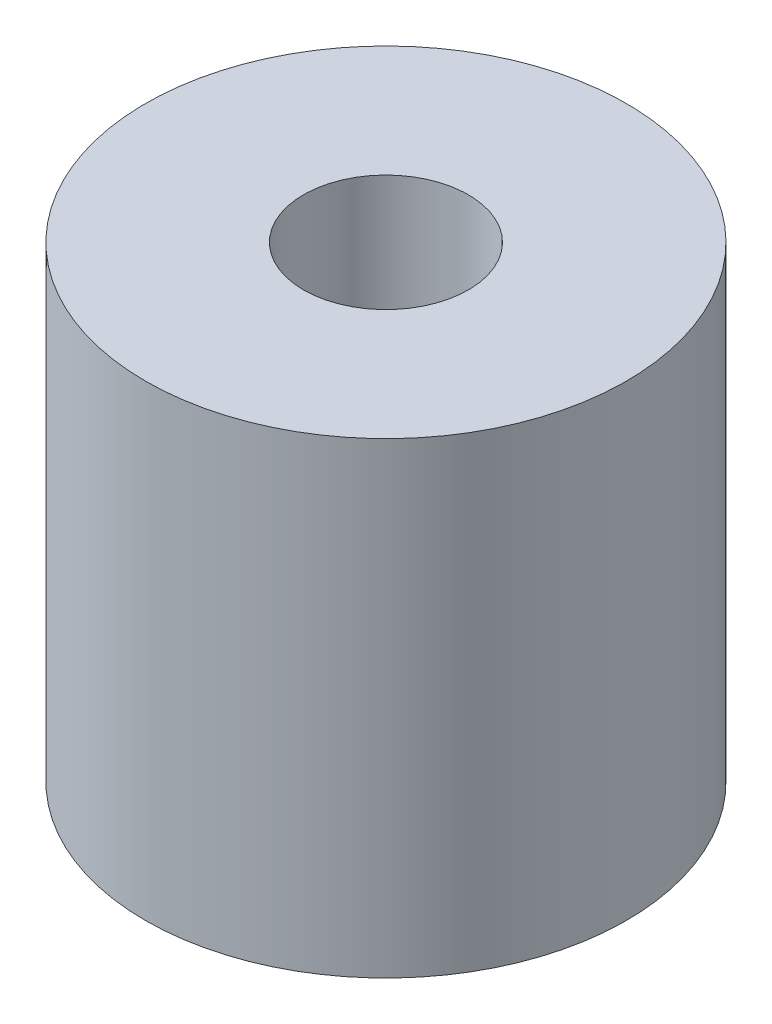
from build123d import *

# Parameters (mm, degrees)
SKETCH1_R           = 35
SKETCH1_R_2         = 12
BOSS_EXTRUDE1_DEPTH = 68


with BuildPart() as part:
    # Sketch1 → Boss-Extrude1 (new body)
    with BuildSketch(Plane(origin=(0, 0, 0), x_dir=(1, 0, 0), z_dir=(0, 1, 0))):
        Circle(SKETCH1_R)
        Circle(SKETCH1_R_2, mode=Mode.SUBTRACT)
    extrude(amount=BOSS_EXTRUDE1_DEPTH)


solid = part.part
